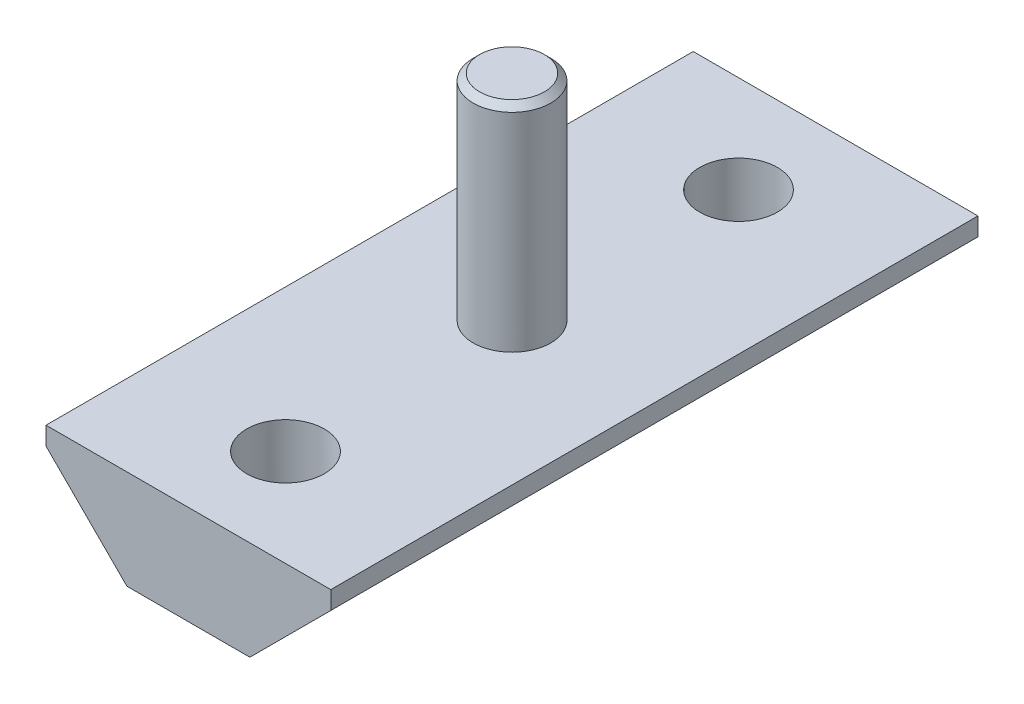
from build123d import *

# Parameters (mm, degrees)
BOSS_EXTRUDE1_DEPTH = 25
SKETCH2_R           = 3
BOSS_EXTRUDE2_DEPTH = 16.55
SKETCH3_R           = 3
CUT_EXTRUDE1_DEPTH  = 10
CHAMFER1_SIZE       = 0.5


with BuildPart() as part:
    # Sketch1 → Boss-Extrude1 (new body, symmetric)
    with BuildSketch(Plane.XY):
        Polygon((11, 7.65), (-11, 7.65), (-11, 6.25), (-4.75, 0), (4.75, 0), (11, 6.25), align=None)
    extrude(amount=BOSS_EXTRUDE1_DEPTH, both=True)

    # Sketch2 → Boss-Extrude2 (add)
    with BuildSketch(Plane(origin=(0, 7.65, 0), x_dir=(1, 0, 0), z_dir=(0, 1, 0))):
        Circle(SKETCH2_R)
    extrude(amount=BOSS_EXTRUDE2_DEPTH)

    # Sketch3 → Cut-Extrude1 (cut)
    with BuildSketch(Plane(origin=(0, 7.65, 0), x_dir=(1, 0, 0), z_dir=(0, 1, 0))):
        with Locations((0, 17.5)):
            Circle(SKETCH3_R)
        with Locations((0, -17.5)):
            Circle(SKETCH3_R)
    extrude(amount=-CUT_EXTRUDE1_DEPTH, mode=Mode.SUBTRACT)

    # Chamfer1
    chamfer1_edges = [part.edges().sort_by_distance(p)[0] for p in [
        (-3, 24.2, 0),
    ]]
    chamfer(chamfer1_edges, length=CHAMFER1_SIZE)


solid = part.part
